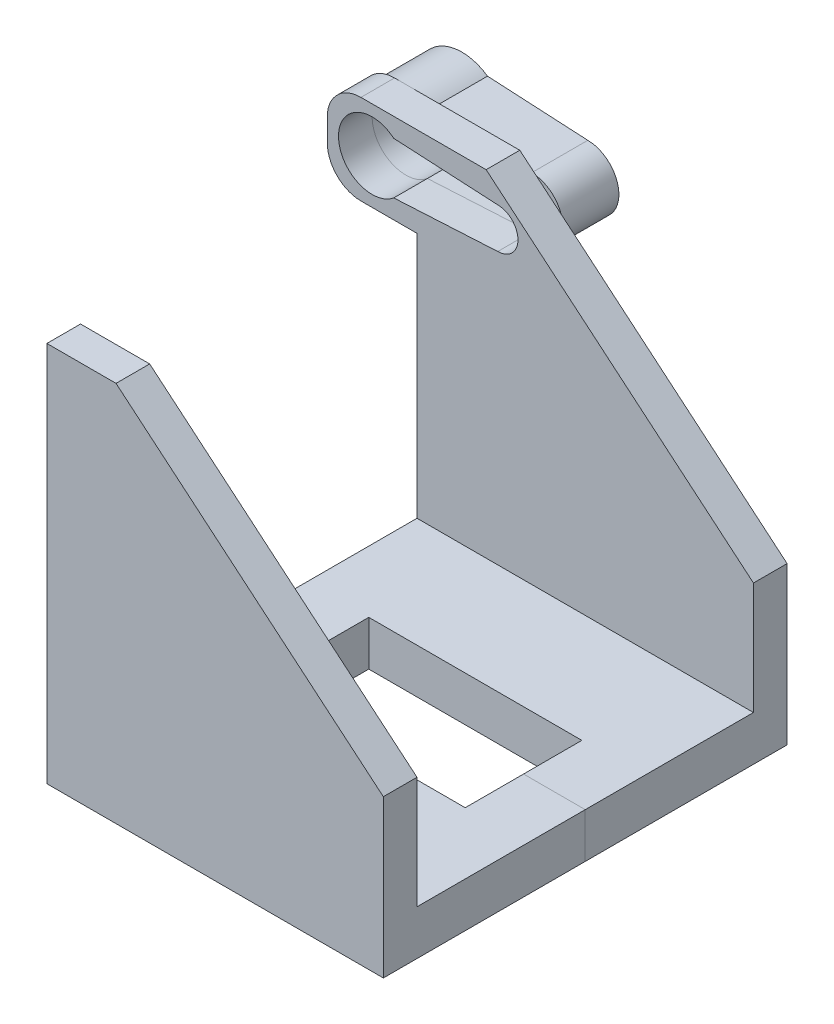
from build123d import *

# Parameters (mm, degrees)
SKETCH1_W           = 38.1
SKETCH1_H           = 45.72
SKETCH1_W_2         = 24.13
SKETCH1_H_2         = 13.208
BOSS_EXTRUDE1_DEPTH = 5.08
SKETCH2_W           = 38.1
SKETCH2_H           = 3.81
BOSS_EXTRUDE2_DEPTH = 38.1
CHAMFER1_SIZE       = 25.4
CHAMFER1_SIZE2      = 30.270541252
SKETCH3_W           = 3.81
SKETCH3_H           = 10.16
BOSS_EXTRUDE3_DEPTH = 10.16
FILLET1_R           = 3.81
EXTRUDE_THIN2_DEPTH = 6.35
CUT_EXTRUDE3_DEPTH  = 3.81


with BuildPart() as part:
    # Sketch1 → Boss-Extrude1 (new body)
    with BuildSketch(Plane(origin=(0, 0, 0), x_dir=(1, 0, 0), z_dir=(0, 1, 0))):
        Rectangle(SKETCH1_W, SKETCH1_H)
        Rectangle(SKETCH1_W_2, SKETCH1_H_2, mode=Mode.SUBTRACT)
    extrude(amount=BOSS_EXTRUDE1_DEPTH)

    # Sketch2 → Boss-Extrude2 (add)
    with BuildSketch(Plane(origin=(0, 5.08, 0), x_dir=(1, 0, 0), z_dir=(0, 1, 0))):
        with Locations((0, 20.955)):
            Rectangle(SKETCH2_W, SKETCH2_H)
        with Locations((0, -20.955)):
            Rectangle(SKETCH2_W, SKETCH2_H)
    extrude(amount=BOSS_EXTRUDE2_DEPTH)

    # Chamfer1
    chamfer1_edges = [part.edges().sort_by_distance(p)[0] for p in [
        (19.05, 43.18, -20.955),
        (19.05, 43.18, 20.955),
    ]]
    chamfer1_side = [part.faces().sort_by_distance(p)[0] for p in [
        (19.05, 21.59, 22.231125545),
    ]]
    chamfer(chamfer1_edges, length=CHAMFER1_SIZE, length2=CHAMFER1_SIZE2, reference=chamfer1_side[0])

    # Sketch3 → Boss-Extrude3 (add)
    with BuildSketch(Plane.ZY.offset(19.05)):
        with Locations((-20.955, 38.1)):
            Rectangle(SKETCH3_W, SKETCH3_H)
    extrude(amount=BOSS_EXTRUDE3_DEPTH)

    # Fillet1
    fillet1_edges = [part.edges().sort_by_distance(p)[0] for p in [
        (-29.21, 33.02, -20.955),
        (-29.21, 43.18, -20.955),
    ]]
    fillet(fillet1_edges, radius=FILLET1_R)

    # Sketch6 → Cut-Extrude3 (cut)
    with BuildSketch(Plane(origin=(0, 0, -22.86), x_dir=(-1, 0, 0), z_dir=(0, 0, -1))):
        with BuildLine():
            Line((9.906, 40.386), (21.683807244, 41.021))
            ThreePointArc((21.683807244, 41.021), (27.94, 38.1), (21.683807244, 35.179))
            Line((21.683807244, 35.179), (9.906, 35.814))
            ThreePointArc((9.906, 35.814), (7.62, 38.1), (9.906, 40.386))
        make_face()
    extrude(amount=-CUT_EXTRUDE3_DEPTH, mode=Mode.SUBTRACT)


with BuildPart() as body_2:
    # Sketch4 → Extrude-Thin2 (new body)
    with BuildSketch(Plane(origin=(0, 0, -22.86), x_dir=(-1, 0, 0), z_dir=(0, 0, -1))):
        with BuildLine():
            Line((9.868028508, 41.655797262), (21.226072609, 42.268165749))
            ThreePointArc((21.226072609, 42.268165749), (29.21, 38.1), (21.226072609, 33.931834251))
            Line((21.226072609, 33.931834251), (9.868028508, 34.544202738))
            ThreePointArc((9.868028508, 34.544202738), (6.35, 38.1), (9.868028508, 41.655797262))
        make_face()
        with BuildLine():
            Line((9.906, 40.386), (21.683807244, 41.021))
            ThreePointArc((21.683807244, 41.021), (27.94, 38.1), (21.683807244, 35.179))
            Line((21.683807244, 35.179), (9.906, 35.814))
            ThreePointArc((9.906, 35.814), (7.62, 38.1), (9.906, 40.386))
        make_face(mode=Mode.SUBTRACT)
    extrude(amount=EXTRUDE_THIN2_DEPTH)


with BuildPart() as body_3:
    # Split1: the piece on the far side of the plane
    add(part.part)
    split(bisect_by=Plane.XY, keep=Keep.BOTTOM)


with BuildPart() as part_1:
    add(part.part)

    # Split1
    split(bisect_by=Plane.XY, keep=Keep.TOP)


solid = Compound([body_2.part, body_3.part, part_1.part])
